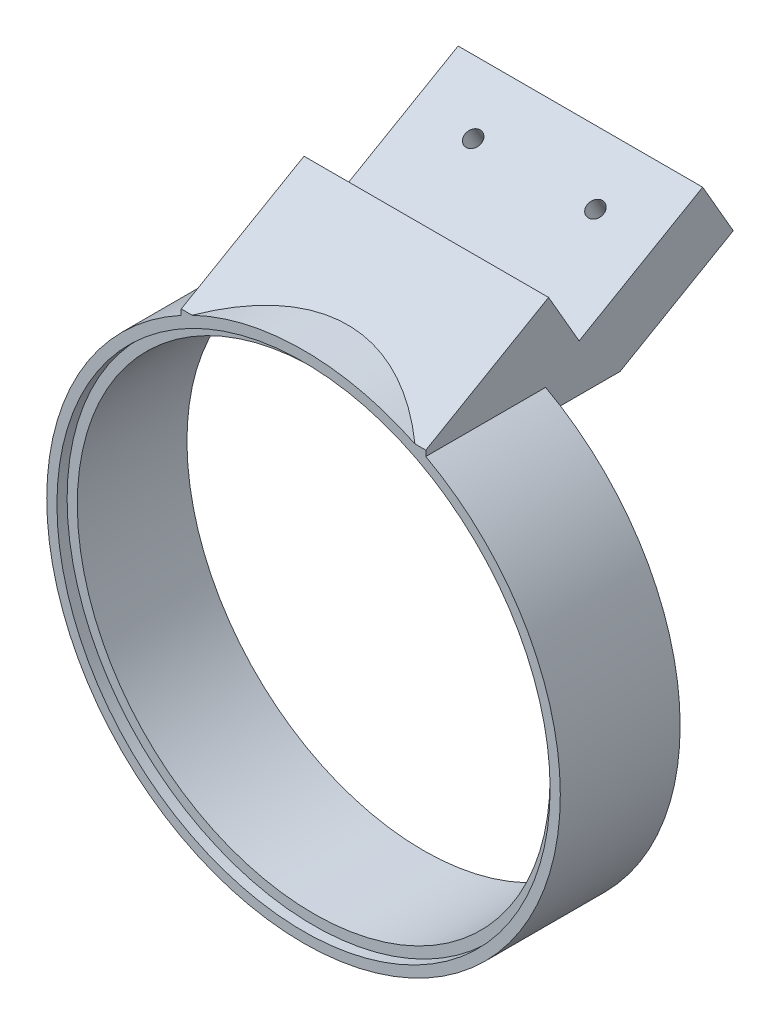
from build123d import *

# Parameters (mm, degrees)
SKETCH1_R                  = 63
SKETCH1_R_2                = 58
BOSS_EXTRUDE1_DEPTH        = 29.4
SKETCH2_R                  = 60.5
SKETCH2_R_2                = 58
CUT_EXTRUDE1_DEPTH         = 2
BOSS_EXTRUDE2_REACH        = 115.821
BOSS_EXTRUDE2_START_RADIUS = 63
BOSS_EXTRUDE2_END_RADIUS   = 63
SKETCH3_W                  = 60
SKETCH3_H                  = 29.4
SKETCH5_W                  = 29.4
SKETCH5_H                  = 24.463774017
CUT_EXTRUDE2_DEPTH         = 60
BOSS_EXTRUDE3_DEPTH        = 60
SKETCH7_W                  = 60
SKETCH7_H                  = 58.8
BOSS_EXTRUDE4_DEPTH        = 50
CUT_EXTRUDE3_REACH         = 184.817
SKETCH9_W                  = 60
SKETCH9_H                  = 50
BOSS_EXTRUDE5_DEPTH        = 31.44
SKETCH10_W                 = 60
SKETCH10_H                 = 31.44
BOSS_EXTRUDE6_DEPTH        = 30
SKETCH11_R                 = 58
CUT_EXTRUDE4_DEPTH         = 167.216683318
SKETCH14_W                 = 60
SKETCH14_H                 = 50.574659949
CUT_EXTRUDE5_DEPTH         = 14.7
CUT_EXTRUDE6_REACH         = 169.252
BOSS_EXTRUDE7_REACH        = 150.201
BOSS_EXTRUDE10_DEPTH       = 60
SKETCH17_R                 = 58
CUT_EXTRUDE7_DEPTH         = 148.031754667
CUT_EXTRUDE7_DEPTH_BACK    = 148.031754667
CUT_EXTRUDE13_START        = -2.5
SKETCH26_R                 = 60.5
SKETCH26_R_2               = 57.5
CUT_EXTRUDE13_DEPTH        = 10
SKETCH27_R                 = 63
SKETCH27_R_2               = 60.5
CUT_EXTRUDE14_DEPTH        = 10
SKETCH28_R                 = 82.177963531
CUT_EXTRUDE15_DEPTH        = 10
SKETCH18_W                 = 60
SKETCH18_H                 = 15
CUT_EXTRUDE8_DEPTH         = 50
SKETCH29_R                 = 2
CUT_EXTRUDE16_DEPTH        = 15
CUT_EXTRUDE17_REACH        = 150.403
SKETCH30_W                 = 60
SKETCH30_H                 = 15


with BuildPart() as part:
    # Sketch1 → Boss-Extrude1 (new body)
    with BuildSketch(Plane.XY):
        Circle(SKETCH1_R)
        Circle(SKETCH1_R_2, mode=Mode.SUBTRACT)
    extrude(amount=BOSS_EXTRUDE1_DEPTH)

    # Sketch2 → Cut-Extrude1 (cut)
    with BuildSketch(Plane.XY.offset(29.4)):
        Circle(SKETCH2_R)
        Circle(SKETCH2_R_2, mode=Mode.SUBTRACT)
    extrude(amount=-CUT_EXTRUDE1_DEPTH, mode=Mode.SUBTRACT)

    # Boss-Extrude2: from a cylinder face, 115.821 long prism both ways, kept between that surface and its translate by the depth
    boss_extrude2_start = Plane(origin=(0, 0, 14.7), z_dir=(0, 0, -1)) * Cylinder(BOSS_EXTRUDE2_START_RADIUS, 358.642, mode=Mode.PRIVATE)
    boss_extrude2_end = Plane(origin=(0, 20, 14.7), z_dir=(0, 0, -1)) * Cylinder(BOSS_EXTRUDE2_END_RADIUS, 358.642, mode=Mode.PRIVATE)
    # Sketch3 → Boss-Extrude2 (add, from a surface)
    with BuildSketch(Plane(origin=(0, 0, 0), x_dir=(1, 0, 0), z_dir=(0, 1, 0)), mode=Mode.PRIVATE) as boss_extrude2_sk1:
        with Locations((0, -14.7)):
            Rectangle(SKETCH3_W, SKETCH3_H)
    boss_extrude2_tool1 = extrude(boss_extrude2_sk1.sketch, amount=BOSS_EXTRUDE2_REACH, both=True, mode=Mode.PRIVATE)
    add(((boss_extrude2_tool1 - boss_extrude2_start) & boss_extrude2_end).solids().sort_by_distance((0, 65.398556, 14.7))[0])

    # Sketch5 → Cut-Extrude2 (cut)
    with BuildSketch(Plane.ZY.offset(30)):
        with Locations((14.7, 87.630442947)):
            Rectangle(SKETCH5_W, SKETCH5_H)
    extrude(amount=-CUT_EXTRUDE2_DEPTH, mode=Mode.SUBTRACT)

    # Sketch6 → Boss-Extrude3 (add)
    with BuildSketch(Plane.ZY.offset(30)):
        Polygon((0, 75.398555938), (29.4, 126.32084968), (29.4, 75.398555938), align=None)
    extrude(amount=-BOSS_EXTRUDE3_DEPTH)

    # Sketch7 → Boss-Extrude4 (add)
    with BuildSketch(Plane(origin=(0, 18.849638984, -32.648532425), x_dir=(1, 0, 0), z_dir=(0, 0.500000000000004, -0.8660254037844364))):
        with Locations((0, -94.697064851)):
            Rectangle(SKETCH7_W, SKETCH7_H)
    extrude(amount=BOSS_EXTRUDE4_DEPTH)

    # Sketch8 → Cut-Extrude3 (cut, up to next)
    with BuildSketch(Plane(origin=(30, 0, 0), x_dir=(0, 0, -1), z_dir=(1, 0, 0)), mode=Mode.PRIVATE) as cut_extrude3_sk1:
        Polygon((28.601270189, 125.859702809), (-29.4, 92.372653852), (-29.4, 126.32084968), (13.901270189, 151.32084968), align=None)
    cut_extrude3_tool1 = extrude(cut_extrude3_sk1.sketch, amount=-CUT_EXTRUDE3_REACH, mode=Mode.PRIVATE) & part.part
    add(cut_extrude3_tool1.solids().sort_by_distance((30, 123.250107, 3.896605))[0], mode=Mode.SUBTRACT)

    # Sketch9 → Boss-Extrude5 (add)
    with BuildSketch(Plane(origin=(0, 56.548916953, 32.648532425), x_dir=(1, 0, 0), z_dir=(0, -0.8660254037844365, -0.500000000000004))):
        with Locations((0, -62.699277969)):
            Rectangle(SKETCH9_W, SKETCH9_H)
    extrude(amount=BOSS_EXTRUDE5_DEPTH)

    # Sketch10 → Boss-Extrude6 (add)
    with BuildSketch(Plane(origin=(0, 18.849638984, -32.648532425), x_dir=(1, 0, 0), z_dir=(0, -0.500000000000004, 0.8660254037844364))):
        with Locations((0, 49.577064851)):
            Rectangle(SKETCH10_W, SKETCH10_H)
    extrude(amount=BOSS_EXTRUDE6_DEPTH)

    # Sketch11 → Cut-Extrude4 (cut, through all)
    with BuildSketch(Plane.XY.offset(29.4)):
        with Locations(Location((0, 0, 0), (0, 0, 121.147389922))):
            Circle(SKETCH11_R)
    extrude(amount=-CUT_EXTRUDE4_DEPTH, mode=Mode.SUBTRACT)

    # Sketch14 → Cut-Extrude5 (cut)
    with BuildSketch(Plane.XY.offset(29.4)):
        with Locations((0, 117.659983826)):
            Rectangle(SKETCH14_W, SKETCH14_H)
        with BuildLine():
            ThreePointArc((30, 55.398555938), (0, 63), (-30, 55.398555938))
            Line((-30, 55.398555938), (-30, 92.372653852))
            Line((-30, 92.372653852), (30, 92.372653852))
            Line((30, 92.372653852), (30, 55.398555938))
        make_face()
    extrude(amount=-CUT_EXTRUDE5_DEPTH, mode=Mode.SUBTRACT)

    # Sketch15 → Cut-Extrude6 (cut, up to next)
    with BuildSketch(Plane(origin=(30, 0, 0), x_dir=(0, 0, -1), z_dir=(1, 0, 0)), mode=Mode.PRIVATE) as cut_extrude6_sk1:
        Polygon((44.021270189, 99.151479356), (-14.7, 65.248738206), (-14.7, 100.859702809), (28.601270189, 125.859702809), align=None)
    cut_extrude6_tool1 = extrude(cut_extrude6_sk1.sketch, amount=-CUT_EXTRUDE6_REACH, mode=Mode.PRIVATE) & part.part
    add(cut_extrude6_tool1.solids().sort_by_distance((30, 96.99498, -10.999854))[0], mode=Mode.SUBTRACT)

    # Boss-Extrude7: up to this face of the body (flat: up to its plane)
    boss_extrude7_end = Plane(part.part.faces().sort_by_distance((-30, 70.930733499, -23.393070455))[0])
    # Sketch16 → Boss-Extrude7 (add, up to the picked face)
    with BuildSketch(Plane(origin=(30, 0, 0), x_dir=(0, 0, -1), z_dir=(1, 0, 0)), mode=Mode.PRIVATE) as boss_extrude7_sk1:
        Polygon((-17.904609691, 55.398555938), (-14.7, 55.398555938), (-14.7, 65.248738206), (-17.904609691, 63.398555938), align=None)
    boss_extrude7_tool1 = split(extrude(boss_extrude7_sk1.sketch, amount=-BOSS_EXTRUDE7_REACH, mode=Mode.PRIVATE), bisect_by=boss_extrude7_end, keep=Keep.BOTH, mode=Mode.PRIVATE)
    add(boss_extrude7_tool1.solids().sort_by(Axis((30, 59.877083, 16.246945), (-1, 0, 0)))[0])

    # Sketch25 → Boss-Extrude10 (add)
    with BuildSketch(Plane(origin=(30, 0, 0), x_dir=(0, 0, -1), z_dir=(1, 0, 0))):
        Polygon((-17.904609691, 55.398555938), (-31.761016151, 55.398555938), (-17.904609691, 63.398555938), align=None)
    extrude(amount=-BOSS_EXTRUDE10_DEPTH)

    # Sketch17 → Cut-Extrude7 (cut, two sides)
    with BuildSketch(Plane.XY.offset(29.4)) as cut_extrude7_sk:
        with Locations(Location((0, 0, 0), (0, 0, 121.147389922))):
            Circle(SKETCH17_R)
    extrude(amount=CUT_EXTRUDE7_DEPTH, mode=Mode.SUBTRACT)
    extrude(cut_extrude7_sk.sketch, amount=-CUT_EXTRUDE7_DEPTH_BACK, mode=Mode.SUBTRACT)

    # Sketch26 → Cut-Extrude13 (cut)
    with BuildSketch(Plane.XY.offset(29.4).offset(CUT_EXTRUDE13_START)):
        Circle(SKETCH26_R)
        Circle(SKETCH26_R_2, mode=Mode.SUBTRACT)
    extrude(amount=CUT_EXTRUDE13_DEPTH, mode=Mode.SUBTRACT)

    # Sketch27 → Cut-Extrude14 (cut)
    with BuildSketch(Plane.XY.offset(29.4)):
        Circle(SKETCH27_R)
        Circle(SKETCH27_R_2, mode=Mode.SUBTRACT)
    extrude(amount=CUT_EXTRUDE14_DEPTH, mode=Mode.SUBTRACT)

    # Sketch28 → Cut-Extrude15 (cut)
    with BuildSketch(Plane.XY.offset(29.4)):
        Circle(SKETCH28_R)
    extrude(amount=CUT_EXTRUDE15_DEPTH, mode=Mode.SUBTRACT)

    # Sketch18 → Cut-Extrude8 (cut)
    with BuildSketch(Plane(origin=(0, 43.849638984, -75.949802615), x_dir=(1, 0, 0), z_dir=(0, 0.500000000000004, -0.8660254037844364))):
        with Locations((0, -56.357064851)):
            Rectangle(SKETCH18_W, SKETCH18_H)
    extrude(amount=-CUT_EXTRUDE8_DEPTH, mode=Mode.SUBTRACT)

    # Sketch29 → Cut-Extrude16 (cut)
    with BuildSketch(Plane(origin=(0, 29.321078258, 16.928532425), x_dir=(1, 0, 0), z_dir=(0, -0.8660254037844362, -0.5000000000000041))):
        with Locations(Location((-15, -59.636899675, 0), (0, 0, 270))):
            Circle(SKETCH29_R)
        with Locations(Location((15, -59.636899675, 0), (0, 0, 270))):
            Circle(SKETCH29_R)
    extrude(amount=-CUT_EXTRUDE16_DEPTH, mode=Mode.SUBTRACT)

    # Sketch30 → Cut-Extrude17 (cut, up to next)
    with BuildSketch(Plane(origin=(0, 42.311459315, 24.428532425), x_dir=(1, 0, 0), z_dir=(0, 0.8660254037844364, 0.5000000000000041)), mode=Mode.PRIVATE) as cut_extrude17_sk1:
        with Locations((0, 80.199277969)):
            Rectangle(SKETCH30_W, SKETCH30_H)
    cut_extrude17_tool1 = extrude(cut_extrude17_sk1.sketch, amount=-CUT_EXTRUDE17_REACH, mode=Mode.PRIVATE) & part.part
    add(cut_extrude17_tool1.solids().sort_by_distance((0, 82.411098, -45.02608))[0], mode=Mode.SUBTRACT)


solid = part.part
